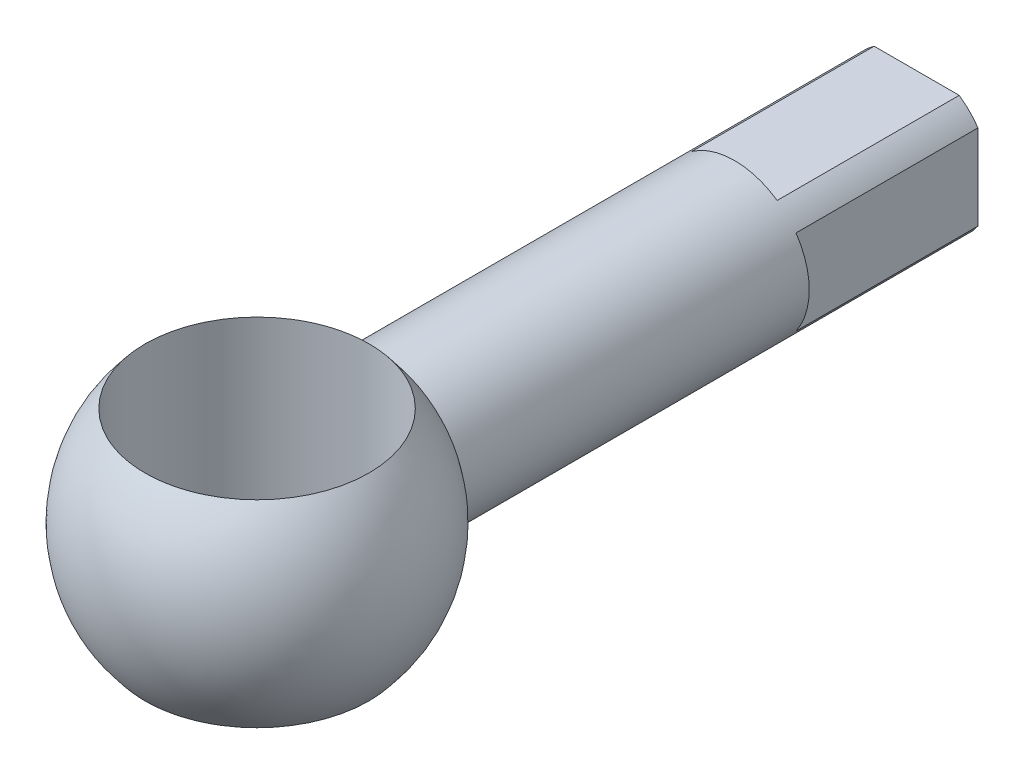
from build123d import *

# Parameters (mm, degrees)
SKETCH3_R               = 19.05
CUT_EXTRUDE1_DEPTH      = 26.4
CUT_EXTRUDE1_DEPTH_BACK = 26.4
CUT_EXTRUDE2_DEPTH      = 30.988


with BuildPart() as part:
    # Sketch2 → Revolve2 (revolve)
    with BuildSketch(Plane(origin=(0, 0, 0), x_dir=(1, 0, 0), z_dir=(0, 1, 0))):
        with BuildLine():
            Line((0, -64.870503597), (0, 72.797496403))
            Line((0, 72.797496403), (-12.7, 72.797496403))
            Line((-12.7, 72.797496403), (-12.7, -17.473458341))
            ThreePointArc((-12.7, -17.473458341), (-24.534515988, -46.044507343), (0, -64.870503597))
        make_face()
    revolve(axis=Axis((0, 0, -52.444604317), (0, 0, 1)))

    # Sketch3 → Cut-Extrude1 (cut, two sides)
    with BuildSketch(Plane(origin=(0, 0, 0), x_dir=(1, 0, 0), z_dir=(0, 1, 0))) as cut_extrude1_sk:
        with Locations((0, -39.470503597)):
            Circle(SKETCH3_R)
    extrude(amount=CUT_EXTRUDE1_DEPTH, mode=Mode.SUBTRACT)
    extrude(cut_extrude1_sk.sketch, amount=-CUT_EXTRUDE1_DEPTH_BACK, mode=Mode.SUBTRACT)

    # Sketch4 → Cut-Extrude2 (cut)
    with BuildSketch(Plane(origin=(0, 0, -72.797496403), x_dir=(-1, 0, 0), z_dir=(0, 0, -1))):
        with BuildLine():
            Line((-7.239, -10.434887589), (7.239, -10.434887589))
            ThreePointArc((7.239, -10.434887589), (0, -12.7), (-7.239, -10.434887589))
        make_face()
        with BuildLine():
            Line((10.434887589, 7.239), (10.434887589, -7.239))
            ThreePointArc((10.434887589, -7.239), (12.7, 0), (10.434887589, 7.239))
        make_face()
        with BuildLine():
            Line((-10.434887589, 7.239), (-10.434887589, -7.239))
            ThreePointArc((-10.434887589, -7.239), (-12.7, 0), (-10.434887589, 7.239))
        make_face()
        with BuildLine():
            Line((-7.239, 10.434887589), (7.239, 10.434887589))
            ThreePointArc((7.239, 10.434887589), (0, 12.7), (-7.239, 10.434887589))
        make_face()
    extrude(amount=-CUT_EXTRUDE2_DEPTH, mode=Mode.SUBTRACT)


solid = part.part
